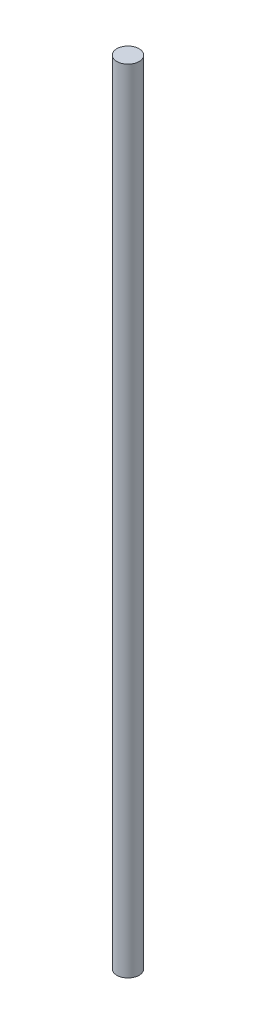
from build123d import *

# Parameters (mm, degrees)
SKETCH1_R           = 2.5
BOSS_EXTRUDE1_DEPTH = 177.8


with BuildPart() as part:
    # Sketch1 → Boss-Extrude1 (new body)
    with BuildSketch(Plane(origin=(0, 0, 0), x_dir=(1, 0, 0), z_dir=(0, 1, 0))):
        Circle(SKETCH1_R)
    extrude(amount=BOSS_EXTRUDE1_DEPTH)


solid = part.part
